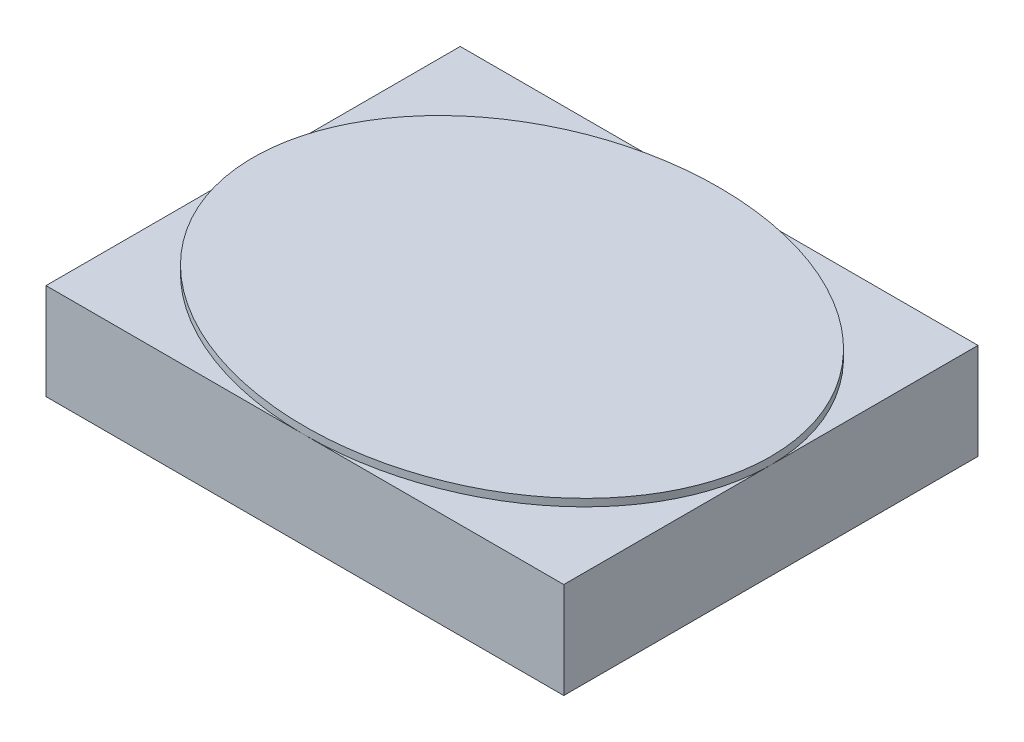
from build123d import *

# Parameters (mm, degrees)
SKETCH1_W           = 3.5
SKETCH1_H           = 2.8
BOSS_EXTRUDE1_DEPTH = 0.65
SKETCH3_RX          = 1.75
SKETCH3_RY          = 1.4
BOSS_EXTRUDE2_DEPTH = 0.05


with BuildPart() as part:
    # Sketch1 → Boss-Extrude1 (new body)
    with BuildSketch(Plane(origin=(0, 0, 0), x_dir=(1, 0, 0), z_dir=(0, 1, 0))):
        with Locations((1.75, 1.4)):
            Rectangle(SKETCH1_W, SKETCH1_H)
    extrude(amount=BOSS_EXTRUDE1_DEPTH)

    # Sketch3 → Boss-Extrude2 (add)
    with BuildSketch(Plane(origin=(0, 0.65, 0), x_dir=(1, 0, 0), z_dir=(0, 1, 0))):
        with Locations((1.75, 1.4)):
            Ellipse(SKETCH3_RX, SKETCH3_RY)
    extrude(amount=BOSS_EXTRUDE2_DEPTH)


solid = part.part
